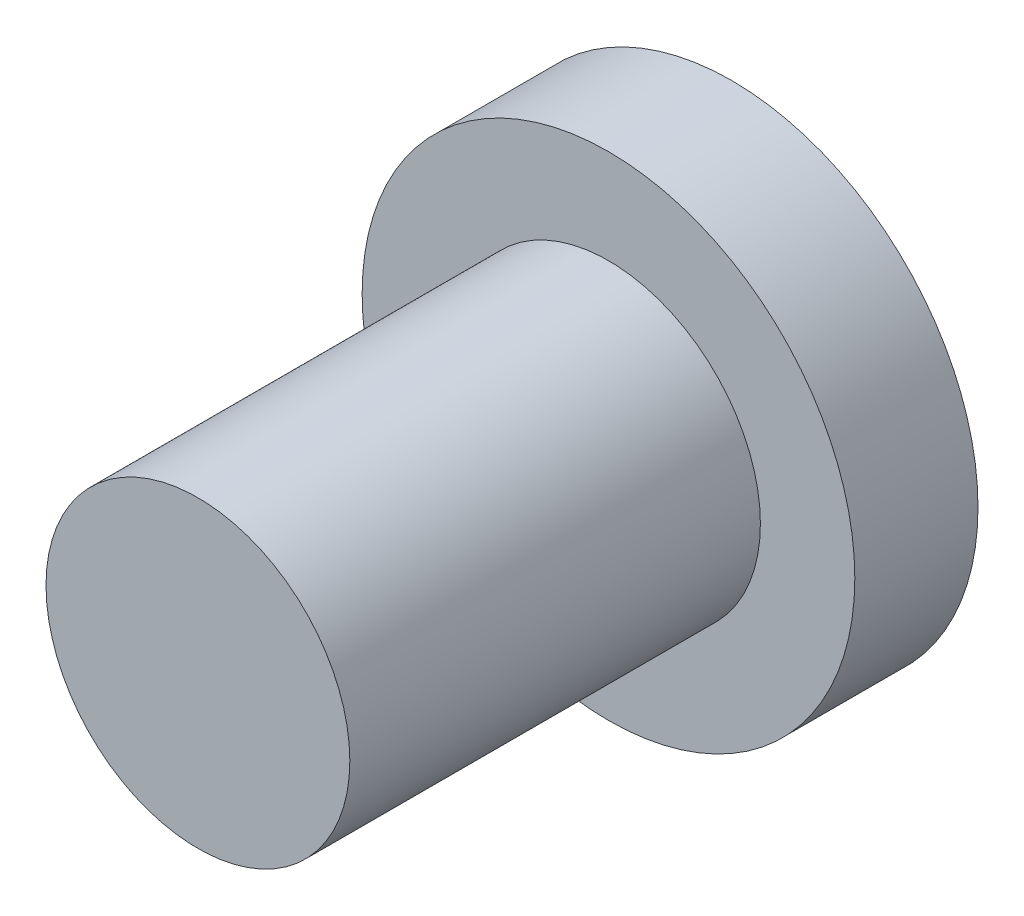
from build123d import *

# Parameters (mm, degrees)
SKETCH1_R           = 6
BOSS_EXTRUDE1_DEPTH = 1.5
SKETCH2_R           = 3.7
BOSS_EXTRUDE2_DEPTH = 10


with BuildPart() as part:
    # Sketch1 → Boss-Extrude1 (new body, symmetric)
    with BuildSketch(Plane.XY):
        Circle(SKETCH1_R)
    extrude(amount=BOSS_EXTRUDE1_DEPTH, both=True)

    # Sketch2 → Boss-Extrude2 (add)
    with BuildSketch(Plane.XY.offset(1.5)):
        Circle(SKETCH2_R)
    extrude(amount=BOSS_EXTRUDE2_DEPTH)


solid = part.part
